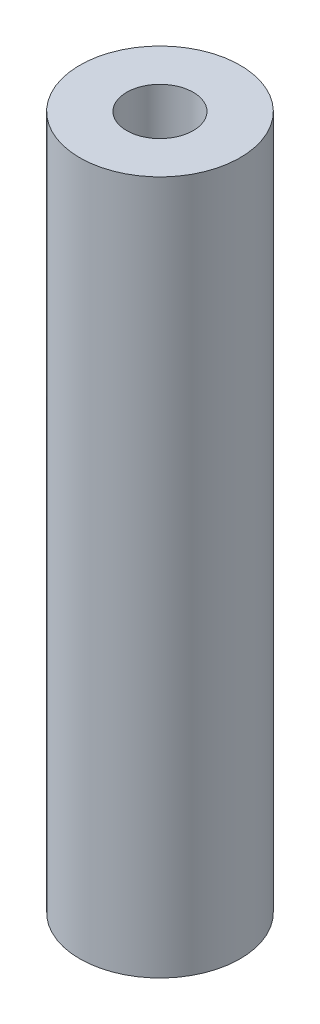
from build123d import *

# Parameters (mm, degrees)
SKETCH2_R                 = 3.9751
BOSS_EXTRUDE1_DEPTH       = 17.2
M4X0_7_TAPPED_HOLE1_D     = 3.3
M4X0_7_TAPPED_HOLE1_DEPTH = 10
M4X0_7_TAPPED_HOLE1_TIP   = 0.991420021
M4X0_7_TAPPED_HOLE2_D     = 3.3
M4X0_7_TAPPED_HOLE2_DEPTH = 10
M4X0_7_TAPPED_HOLE2_TIP   = 0.991420021


with BuildPart() as part:
    # Sketch2 → Boss-Extrude1 (new body, symmetric)
    with BuildSketch(Plane(origin=(0, 0, 0), x_dir=(1, 0, 0), z_dir=(0, 1, 0))):
        Circle(SKETCH2_R)
    extrude(amount=BOSS_EXTRUDE1_DEPTH, both=True)

    # M4x0.7 Tapped Hole1
    with Locations(Plane(origin=(0, 17.2, 0), x_dir=(1, 0, 0), z_dir=(0, 1, 0))):
        with Locations((0, 0)):
            Hole(M4X0_7_TAPPED_HOLE1_D / 2, depth=M4X0_7_TAPPED_HOLE1_DEPTH)
            with Locations((0, 0, -(M4X0_7_TAPPED_HOLE1_DEPTH + M4X0_7_TAPPED_HOLE1_TIP / 2))):  # 118° drill point
                Cone(0, M4X0_7_TAPPED_HOLE1_D / 2, M4X0_7_TAPPED_HOLE1_TIP, mode=Mode.SUBTRACT)

    # M4x0.7 Tapped Hole2
    with Locations(Plane(origin=(0, -17.2, 0), x_dir=(-1, 0, 0), z_dir=(0, -1, 0))):
        with Locations((0, 0)):
            Hole(M4X0_7_TAPPED_HOLE2_D / 2, depth=M4X0_7_TAPPED_HOLE2_DEPTH)
            with Locations((0, 0, -(M4X0_7_TAPPED_HOLE2_DEPTH + M4X0_7_TAPPED_HOLE2_TIP / 2))):  # 118° drill point
                Cone(0, M4X0_7_TAPPED_HOLE2_D / 2, M4X0_7_TAPPED_HOLE2_TIP, mode=Mode.SUBTRACT)


solid = part.part
